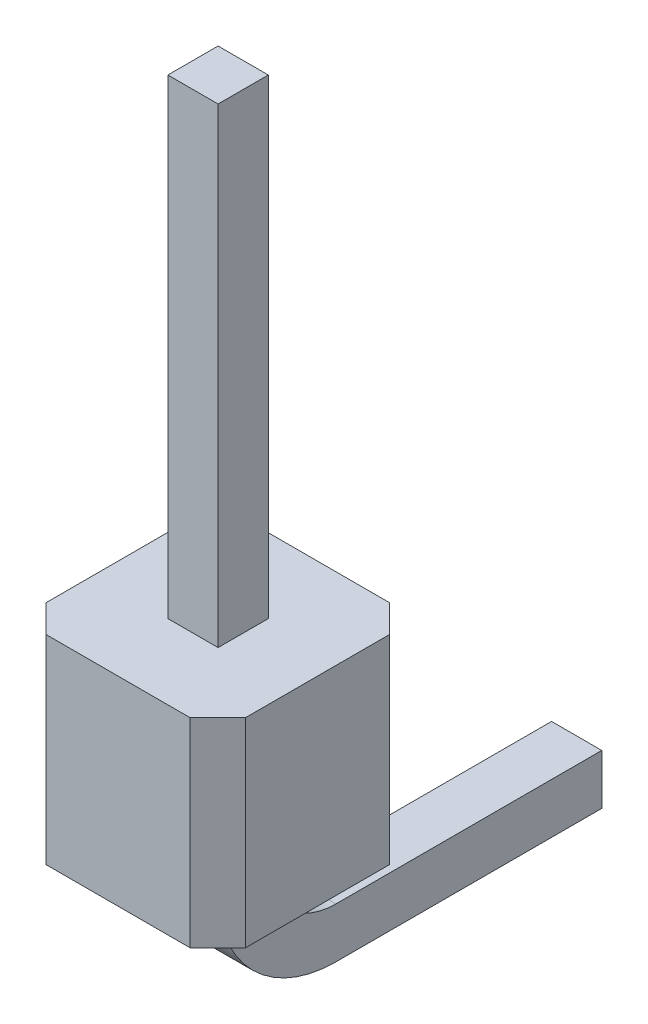
from build123d import *

# Parameters (mm, degrees)
SKETCH1_W           = 0.636
SKETCH1_H           = 0.636
BOSS_EXTRUDE1_DEPTH = 2.54
BOSS_EXTRU_1_DEPTH  = 0.64


with BuildPart() as part:
    # Sketch1 → Boss-Extrude1 (new body)
    with BuildSketch(Plane.XZ):
        Polygon((-0.353553391, -2.186446609), (-2.186446609, -2.186446609), (-2.54, -1.832893219), (-2.54, 0), (-2.186446609, 0.353553391), (-0.353553391, 0.353553391), (0, 0), (0, -1.832893219), align=None)
        with Locations((-1.27, -0.916446609)):
            Rectangle(SKETCH1_W, SKETCH1_H, mode=Mode.SUBTRACT)
    extrude(amount=-BOSS_EXTRUDE1_DEPTH)

    # Esquisse1 → Boss.-Extru.1 (add)
    with BuildSketch(Plane(origin=(-1.588, 0, 0), x_dir=(0, 0, -1), z_dir=(1, 0, 0))):
        with BuildLine():
            Line((0.598446609, 8.54), (0.598446609, -0.18))
            ThreePointArc((0.598446609, -0.18), (1.037786438, -1.240660172), (2.098446609, -1.68))
            Line((2.098446609, -1.68), (5.488446609, -1.68))
            Line((5.488446609, -1.68), (5.488446609, -1.04))
            Line((5.488446609, -1.04), (2.098446609, -1.04))
            ThreePointArc((2.098446609, -1.04), (1.490334778, -0.788111832), (1.238446609, -0.18))
            Line((1.238446609, -0.18), (1.238446609, 8.54))
            Line((1.238446609, 8.54), (0.598446609, 8.54))
        make_face()
    extrude(amount=BOSS_EXTRU_1_DEPTH)


solid = part.part
